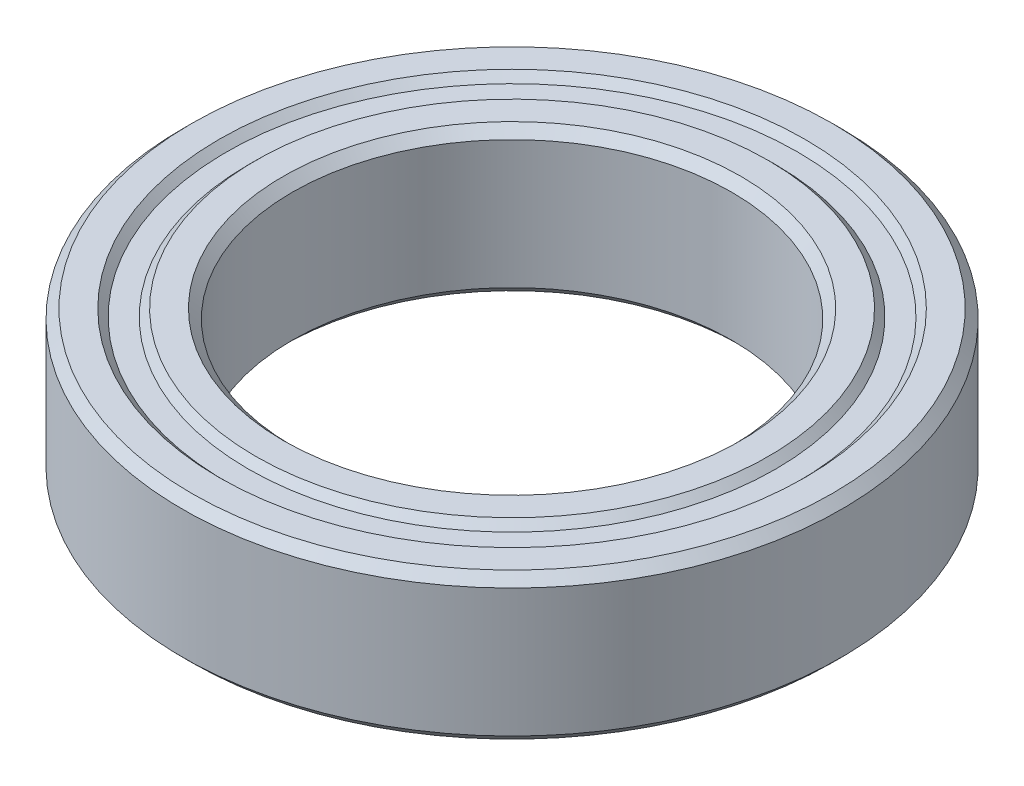
from build123d import *


with BuildPart() as part:
    # Sketch1 → Revolve1 (revolve)
    with BuildSketch(Plane.XY):
        Polygon((6, 1.75), (6, -1.75), (6.25, -2), (7, -2), (7.2, -1.8), (7.8, -1.8), (8, -2), (8.75, -2), (9, -1.75), (9, 1.75), (8.75, 2), (8, 2), (7.8, 1.8), (7.2, 1.8), (7, 2), (6.25, 2), align=None)
    revolve(axis=Axis((0, -1.349421972, 0), (0, 1, 0)))


solid = part.part
